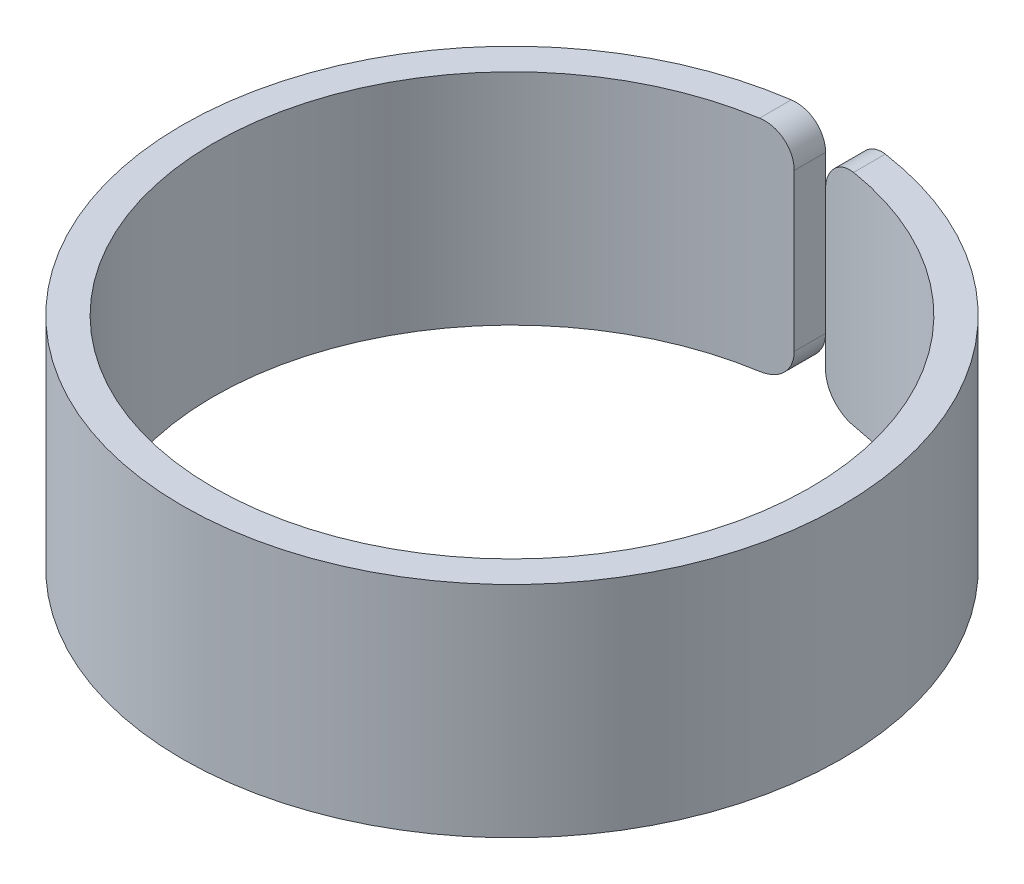
from build123d import *

# Parameters (mm, degrees)
SKETCH3_R               = 10.52
SKETCH3_R_2             = 9.52
EXTRUDE_THIN1_DEPTH     = 3.5
SKETCH4_W               = 1
SKETCH4_H               = 1000
CUT_EXTRUDE1_DEPTH      = 4.5
CUT_EXTRUDE1_DEPTH_BACK = 4.5
FILLET1_R               = 1


with BuildPart() as part:
    # Sketch3 → Extrude-Thin1 (new body, symmetric)
    with BuildSketch(Plane(origin=(0, 0, 0), x_dir=(1, 0, 0), z_dir=(0, 1, 0))):
        Circle(SKETCH3_R)
        Circle(SKETCH3_R_2, mode=Mode.SUBTRACT)
    extrude(amount=EXTRUDE_THIN1_DEPTH, both=True)

    # Sketch4 → Cut-Extrude1 (cut, two sides)
    with BuildSketch(Plane(origin=(0, 0, 0), x_dir=(1, 0, 0), z_dir=(0, 1, 0))) as cut_extrude1_sk:
        with Locations((0, 500)):
            Rectangle(SKETCH4_W, SKETCH4_H)
    extrude(amount=CUT_EXTRUDE1_DEPTH, mode=Mode.SUBTRACT)
    extrude(cut_extrude1_sk.sketch, amount=-CUT_EXTRUDE1_DEPTH_BACK, mode=Mode.SUBTRACT)

    # Fillet1
    fillet1_edges = [part.edges().sort_by_distance(p)[0] for p in [
        (0.5, -3.5, -10.007485917),
        (-0.5, -3.5, -10.007485917),
        (0.5, 3.5, -10.007485917),
        (-0.5, 3.5, -10.007485917),
    ]]
    fillet(fillet1_edges, radius=FILLET1_R)


solid = part.part
